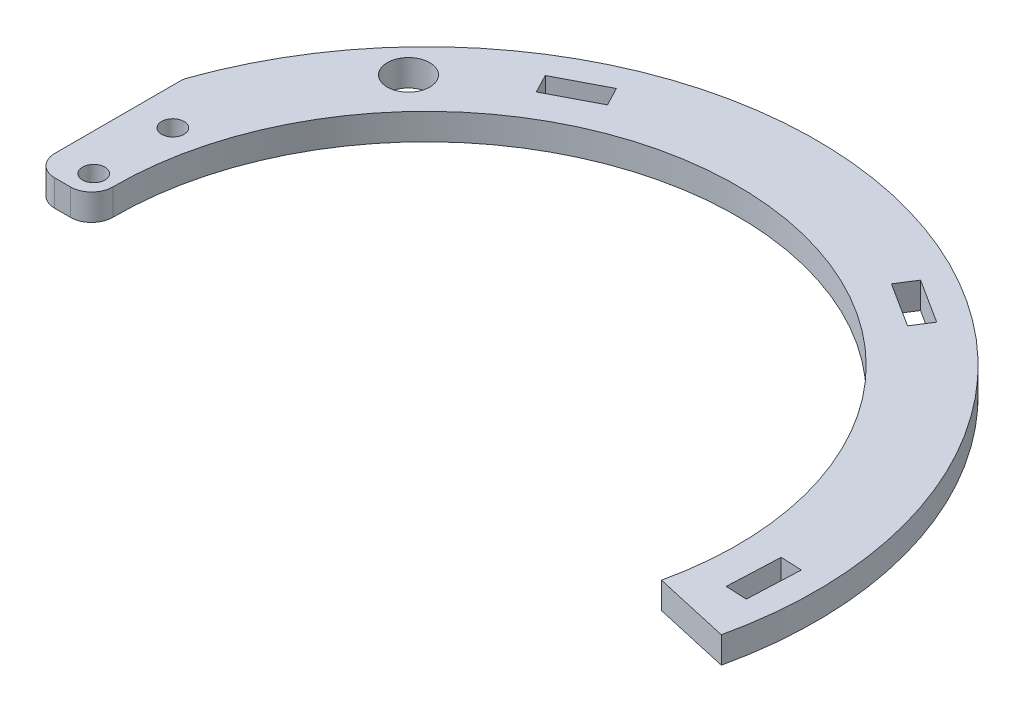
from build123d import *

# Parameters (mm, degrees)
SKETCH1_R               = 4.025
SKETCH1_R_2             = 2.125
BOSS_EXTRUDE1_DEPTH     = 5
SKETCH2_W               = 28.904595792
SKETCH2_H               = 55.332112
CUT_EXTRUDE1_DEPTH      = 1
CUT_EXTRUDE1_DEPTH_BACK = 6
SKETCH3_W               = 24.207106467
SKETCH3_H               = 21.100530829
CUT_EXTRUDE2_DEPTH      = 1
CUT_EXTRUDE2_DEPTH_BACK = 6
FILLET1_R               = 4
BOSS_EXTRUDE2_DEPTH     = 5
CUT_EXTRUDE3_DEPTH      = 6
CIRPATTERN1_COUNT       = 3
CIRPATTERN1_ANGLE       = 120


with BuildPart() as part:
    # Sketch1 → Boss-Extrude1 (new body)
    with BuildSketch(Plane(origin=(0, 0, 0), x_dir=(1, 0, 0), z_dir=(0, 1, 0))):
        with BuildLine():
            Line((-47.75734818, 56.526415903), (-38.07680463, 45.068358625))
            ThreePointArc((-38.07680463, 45.068358625), (-56.716415256, 16.255714087), (-56.169167779, -18.056151058))
            Line((-56.169167779, -18.056151058), (-70.449464672, -22.646697938))
            ThreePointArc((-70.449464672, -22.646697938), (-71.135842864, 20.388522754), (-47.75734818, 56.526415903))
        make_face()
        with Locations((-49.366374859, 46.034889304)):
            Circle(SKETCH1_R, mode=Mode.SUBTRACT)
        with Locations((-63, 0)):
            Circle(SKETCH1_R_2, mode=Mode.SUBTRACT)
        with Locations((-63, -15)):
            Circle(SKETCH1_R_2, mode=Mode.SUBTRACT)
        with Locations((-63, 15)):
            Circle(SKETCH1_R_2, mode=Mode.SUBTRACT)
    extrude(amount=BOSS_EXTRUDE1_DEPTH)

    # Sketch2 → Cut-Extrude1 (cut, two sides)
    with BuildSketch(Plane(origin=(0, 5, 0), x_dir=(1, 0, 0), z_dir=(0, 1, 0))) as cut_extrude1_sk:
        with Locations((-84.452297896, 0)):
            Rectangle(SKETCH2_W, SKETCH2_H)
    extrude(amount=CUT_EXTRUDE1_DEPTH, mode=Mode.SUBTRACT)
    extrude(cut_extrude1_sk.sketch, amount=-CUT_EXTRUDE1_DEPTH_BACK, mode=Mode.SUBTRACT)

    # Sketch3 → Cut-Extrude2 (cut, two sides)
    with BuildSketch(Plane(origin=(0, 5, 0), x_dir=(1, 0, 0), z_dir=(0, 1, 0))) as cut_extrude2_sk:
        with Locations((-57.896446767, -14.949043558)):
            Rectangle(SKETCH3_W, SKETCH3_H)
    extrude(amount=CUT_EXTRUDE2_DEPTH, mode=Mode.SUBTRACT)
    extrude(cut_extrude2_sk.sketch, amount=-CUT_EXTRUDE2_DEPTH_BACK, mode=Mode.SUBTRACT)

    # Fillet1
    fillet1_edges = [part.edges().sort_by_distance(p)[0] for p in [
        (-70, 2.5, -24),
        (-58.835794809, 2.5, 4.398778143),
        (-70, 2.5, 4.398778143),
        (-47.75734818, 2.5, -56.526415903),
        (-38.07680463, 2.5, -45.068358625),
    ]]
    fillet(fillet1_edges, radius=FILLET1_R)

    # Sketch4 → Boss-Extrude2 (add)
    with BuildSketch(Plane(origin=(0, 0, 0), x_dir=(1, 0, 0), z_dir=(0, 1, 0))):
        with BuildLine():
            ThreePointArc((-54.349205626, 50.221149408), (34.402166182, 65.517104347), (72.198801996, -16.227538025))
            Line((72.198801996, -16.227538025), (57.563909699, -12.938172209))
            ThreePointArc((57.563909699, -12.938172209), (25.337317552, 53.282458082), (-46.367196347, 36.484011606))
            Line((-46.367196347, 36.484011606), (-43.532667136, 51.526011005))
            Line((-43.532667136, 51.526011005), (-54.349205626, 50.221149408))
        make_face()
    extrude(amount=BOSS_EXTRUDE2_DEPTH)

    # Sketch5 → Cut-Extrude3 (cut, through all)
    with BuildSketch(Plane(origin=(0, 5, 0), x_dir=(1, 0, 0), z_dir=(0, 1, 0))):
        Polygon((-36.295708479, 58.895004423), (-34.448714026, 55.34696109), (-25.578605694, 59.964447223), (-27.425600147, 63.512490555), align=None)
    cut_extrude3 = extrude(amount=-CUT_EXTRUDE3_DEPTH, mode=Mode.SUBTRACT)

    # CirPattern1: Cut-Extrude3 ×3 about axis
    cirpattern1_axis = Axis((0, 0, 0), (0, -1, 0))
    for i in range(1, CIRPATTERN1_COUNT):
        add(cut_extrude3.rotate(cirpattern1_axis, i * CIRPATTERN1_ANGLE / (CIRPATTERN1_COUNT - 1)), mode=Mode.SUBTRACT)


solid = part.part
